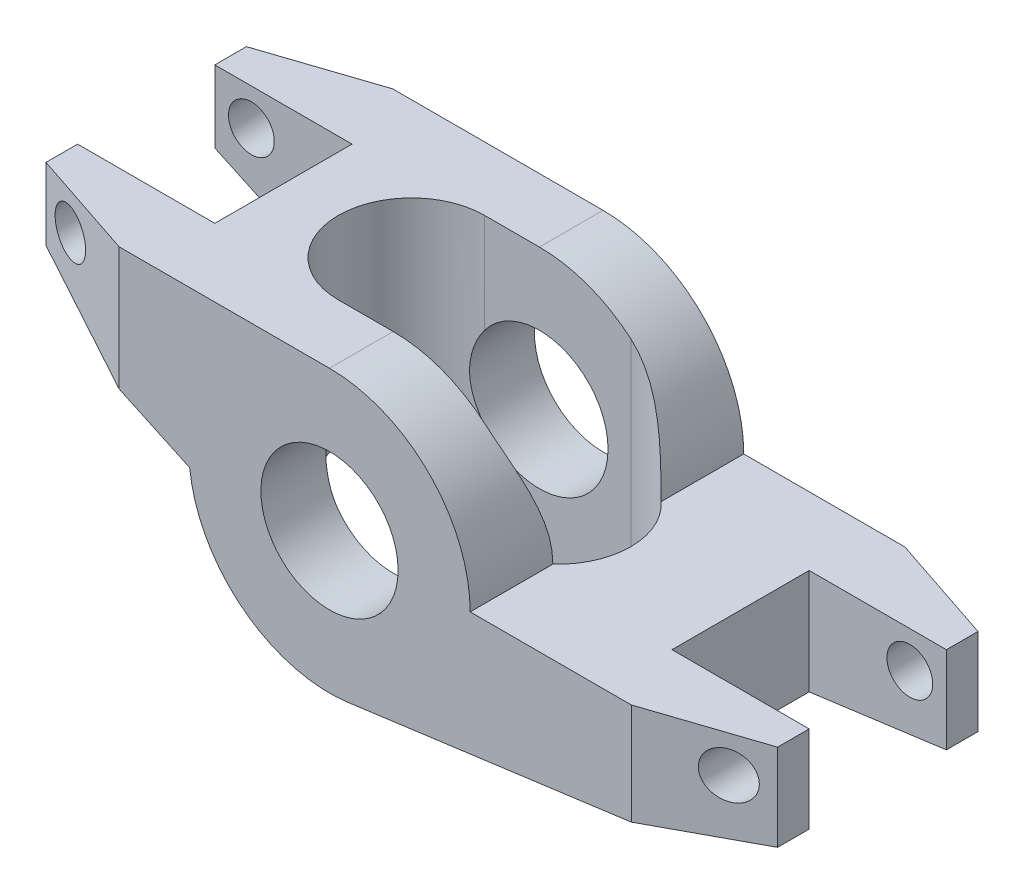
from build123d import *

# Parameters (mm, degrees)
SKETCH1_R               = 4.765
BOSS_EXTRUDE2_DEPTH     = 9.5
CHAMFER1_SIZE           = 2.54
CHAMFER1_SIZE2          = 7.62
CHAMFER1_PART_2_SIZE    = 2.54
CHAMFER1_PART_2_SIZE2   = 7.62
CHAMFER2_SIZE           = 7.62
CHAMFER2_SIZE2          = 2.54
SKETCH3_W               = 9.53
SKETCH3_H               = 9.53
CUT_EXTRUDE1_DEPTH      = 20.54
CUT_EXTRUDE2_DEPTH      = 10.77
CUT_EXTRUDE2_DEPTH_BACK = 10.77
SKETCH5_R               = 1.59
CUT_EXTRUDE3_DEPTH      = 10.5000001
CUT_EXTRUDE3_DEPTH_BACK = 10.5000001


with BuildPart() as part:
    # Sketch1 → Boss-Extrude2 (new body, symmetric)
    with BuildSketch(Plane.XY):
        with BuildLine():
            Line((0, 9.77), (-22.23, 9.77))
            Line((-22.23, 9.77), (-22.23, 4.77))
            Line((-22.23, 4.77), (-9.711509246, -1.067468107))
            ThreePointArc((-9.711509246, -1.067468107), (-6.021421721, -7.693853421), (1.29754109, -9.683454297))
            Line((1.29754109, -9.683454297), (28.58, -6.027722532))
            Line((28.58, -6.027722532), (28.58, 0))
            Line((28.58, 0), (9.77, 0))
            ThreePointArc((9.77, 0), (6.908433252, 6.908433252), (0, 9.77))
        make_face()
        Circle(SKETCH1_R, mode=Mode.SUBTRACT)
    extrude(amount=BOSS_EXTRUDE2_DEPTH, both=True)

    # Chamfer1
    chamfer1_edges = [part.edges().sort_by_distance(p)[0] for p in [
        (-22.23, 7.27, 9.5),
    ]]
    chamfer1_side = [part.faces().sort_by_distance(p)[0] for p in [
        (-22.23, 7.27, 0),
    ]]
    chamfer(chamfer1_edges, length=CHAMFER1_SIZE, length2=CHAMFER1_SIZE2, reference=chamfer1_side[0])

    # Chamfer1 part 2
    chamfer1_part_2_edges = [part.edges().sort_by_distance(p)[0] for p in [
        (28.58, -3.013861266, 9.5),
    ]]
    chamfer1_part_2_side = [part.faces().sort_by_distance(p)[0] for p in [
        (28.58, -3.013861266, 0),
    ]]
    chamfer(chamfer1_part_2_edges, length=CHAMFER1_PART_2_SIZE, length2=CHAMFER1_PART_2_SIZE2, reference=chamfer1_part_2_side[0])

    # Chamfer2
    chamfer2_edges = [part.edges().sort_by_distance(p)[0] for p in [
        (-22.23, 7.27, -9.5),
        (28.58, -3.013861266, -9.5),
    ]]
    chamfer2_side = [part.faces().sort_by_distance(p)[0] for p in [
        (-11.115, 9.225622585, -9.5),
    ]]
    chamfer(chamfer2_edges, length=CHAMFER2_SIZE, length2=CHAMFER2_SIZE2, reference=chamfer2_side[0])

    # Sketch3 → Cut-Extrude1 (cut, through all)
    with BuildSketch(Plane(origin=(0, 9.77, 0), x_dir=(1, 0, 0), z_dir=(0, 1, 0))):
        with Locations((-17.465, 0)):
            Rectangle(SKETCH3_W, SKETCH3_H)
        with Locations((23.815, 0)):
            Rectangle(SKETCH3_W, SKETCH3_H)
    extrude(amount=-CUT_EXTRUDE1_DEPTH, mode=Mode.SUBTRACT)

    # Sketch4 → Cut-Extrude2 (cut, two sides)
    with BuildSketch(Plane(origin=(0, 0, 0), x_dir=(1, 0, 0), z_dir=(0, 1, 0))) as cut_extrude2_sk:
        with BuildLine():
            Line((-3.81, 5.08), (6.35, 5.08))
            ThreePointArc((6.35, 5.08), (11.43, 0), (6.35, -5.08))
            Line((6.35, -5.08), (-3.81, -5.08))
            ThreePointArc((-3.81, -5.08), (-8.89, 0), (-3.81, 5.08))
        make_face()
    extrude(amount=CUT_EXTRUDE2_DEPTH, mode=Mode.SUBTRACT)
    extrude(cut_extrude2_sk.sketch, amount=-CUT_EXTRUDE2_DEPTH_BACK, mode=Mode.SUBTRACT)

    # Sketch5 → Cut-Extrude3 (cut, two sides)
    with BuildSketch(Plane.XY) as cut_extrude3_sk:
        with Locations((-19.69, 7.23)):
            Circle(SKETCH5_R)
        with Locations((26.04, -2.54)):
            Circle(SKETCH5_R)
    extrude(amount=CUT_EXTRUDE3_DEPTH, mode=Mode.SUBTRACT)
    extrude(cut_extrude3_sk.sketch, amount=-CUT_EXTRUDE3_DEPTH_BACK, mode=Mode.SUBTRACT)


solid = part.part
